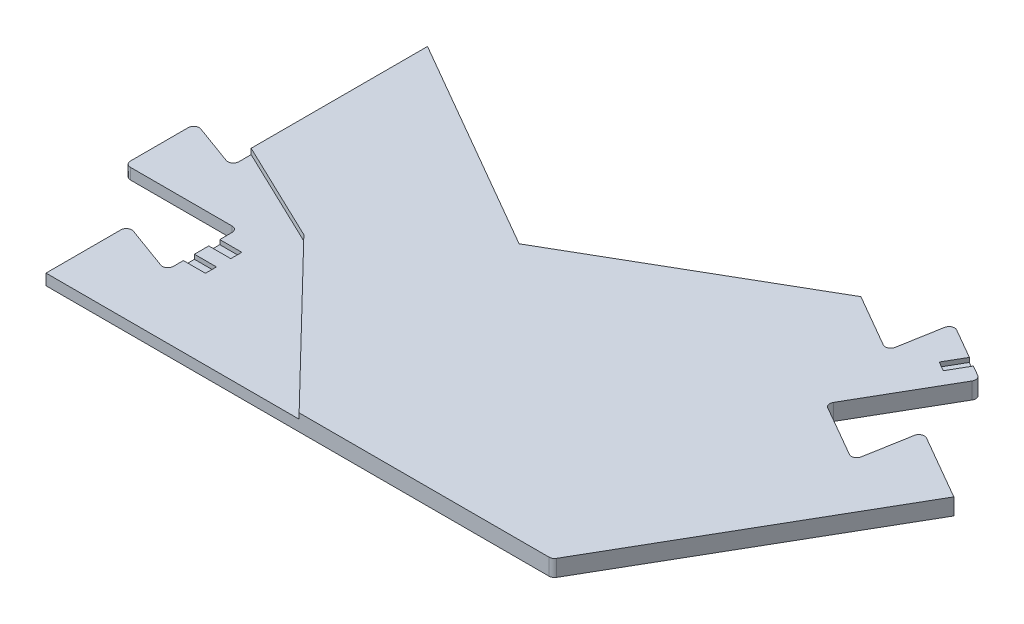
from build123d import *

# Parameters (mm, degrees)
P_IDAT_VYSUNUT_M1_DEPTH  = 3
P_IDAT_VYSUNUT_M2_DEPTH  = 2
ZAOBLIT1_R               = 1
SKICA3_W                 = 4
SKICA3_H                 = 2
ODEBRAT_VYSUNUT_M1_DEPTH = 0.8
ODEBRAT_VYSUNUT_M2_DEPTH = 0.8


with BuildPart() as part:
    # Skica1 → P_idat vysunut_m1 (new body)
    with BuildSketch(Plane(origin=(0, 0, 0), x_dir=(1, 0, 0), z_dir=(0, 1, 0))):
        Polygon((26.667853432, 46.190077074), (13.677472376, 53.690077074), (11.737150801, 42.685966604), (0.392218012, 49.235966604), (10.61747027, 66.946623035), (-0.554257439, 73.396623035), (-2.393036353, 62.968389614), (-13.22114317, 69.22), (-52.538696502, 46.52), (-91.856249834, 69.22), (-91.856249834, 37.22), (-73.49138407, 28.419769911), (-45.928124917, 0), (0, 0), align=None)
    extrude(amount=P_IDAT_VYSUNUT_M1_DEPTH)

    # Skica1_15 → P_idat vysunut_m2 (add)
    with BuildSketch(Plane(origin=(0, 0, 0), x_dir=(1, 0, 0), z_dir=(0, 1, 0))):
        Polygon((13.677472376, 53.690077074), (26.667853432, 46.190077074), (0, 0), (-91.856249834, 0), (-91.856249834, 15), (-81.356249834, 11.17831254), (-81.356249834, 24.27831254), (-101.80675435, 24.27831254), (-101.80675435, 37.17831254), (-91.856249834, 33.55662508), (-91.856249834, 69.22), (-52.538696502, 46.52), (-13.22114317, 69.22), (-2.393036353, 62.968389614), (-0.554257439, 73.396623035), (10.61747027, 66.946623035), (0.392218012, 49.235966604), (11.737150801, 42.685966604), align=None)
    extrude(amount=P_IDAT_VYSUNUT_M2_DEPTH)

    # Zaoblit1
    zaoblit1_edges = [part.edges().sort_by_distance(p)[0] for p in [
        (10.61747027, 1.5, -66.946623035),
        (0.392218012, 1.5, -49.235966604),
        (11.737150801, 1.5, -42.685966604),
        (13.677472376, 1.5, -53.690077074),
        (0, 1.5, 0),
        (-2.393036353, 1.5, -62.968389614),
        (-0.554257439, 1.5, -73.396623035),
        (-91.856249834, 1, -33.55662508),
        (-101.80675435, 1, -37.17831254),
        (-101.80675435, 1, -24.27831254),
        (-81.356249834, 1, -24.27831254),
        (-81.356249834, 1, -11.17831254),
        (-91.856249834, 1, -15),
    ]]
    fillet(zaoblit1_edges, radius=ZAOBLIT1_R)

    # Skica3 → Odebrat vysunut_m1 (cut)
    with BuildSketch(Plane(origin=(0, 2, 0), x_dir=(1, 0, 0), z_dir=(0, 1, 0))):
        with Locations((-79.356249834, 20.02831254)):
            Rectangle(SKICA3_W, SKICA3_H)
        with Locations((-79.356249834, 15.42831254)):
            Rectangle(SKICA3_W, SKICA3_H)
    extrude(amount=-ODEBRAT_VYSUNUT_M1_DEPTH, mode=Mode.SUBTRACT)

    # Skica4 → Odebrat vysunut_m2 (cut)
    with BuildSketch(Plane(origin=(0, 3, 0), x_dir=(1, 0, 0), z_dir=(0, 1, 0))):
        Polygon((4.15743944, 66.05752142), (5.889490248, 65.05752142), (7.889490248, 68.521623035), (6.15743944, 69.521623035), align=None)
    extrude(amount=-ODEBRAT_VYSUNUT_M2_DEPTH, mode=Mode.SUBTRACT)


solid = part.part
